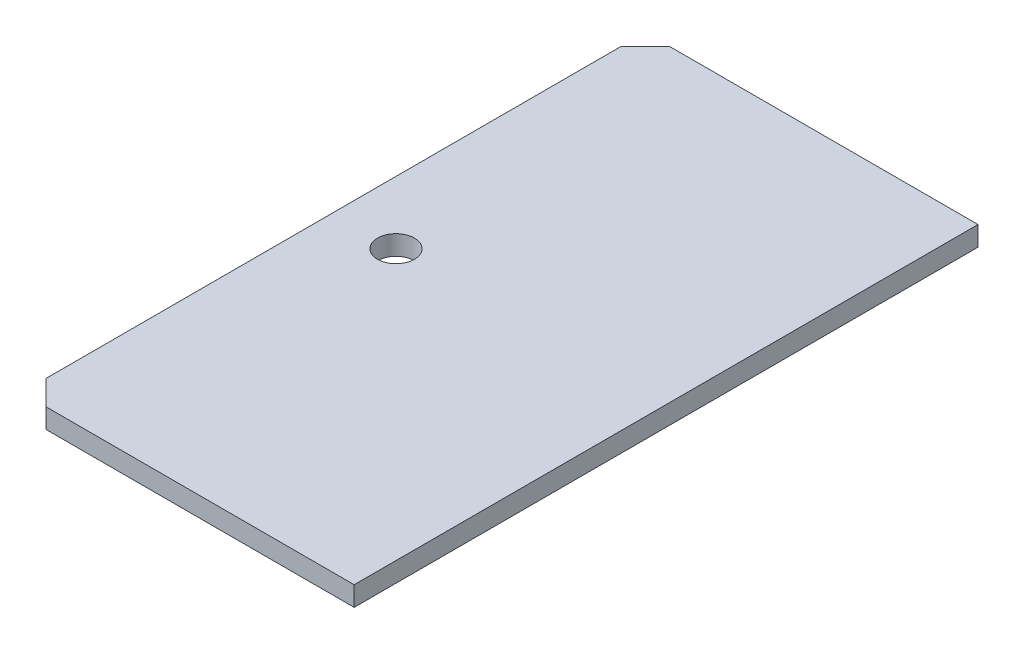
from build123d import *

# Parameters (mm, degrees)
SKETCH1_W           = 81.28
SKETCH1_H           = 50.8
BOSS_EXTRUDE1_DEPTH = 1.6002
SKETCH2_R           = 1.5
CUT_EXTRUDE1_DEPTH  = 1.6002
CHAMFER1_SIZE       = 2
CUT_EXTRUDE2_DEPTH  = 10


with BuildPart() as part:
    # Sketch1 → Boss-Extrude1 (new body)
    with BuildSketch(Plane(origin=(0, 0, 0), x_dir=(1, 0, 0), z_dir=(0, 1, 0))):
        Rectangle(SKETCH1_W, SKETCH1_H)
    extrude(amount=BOSS_EXTRUDE1_DEPTH)

    # Sketch2 → Cut-Extrude1 (cut)
    with BuildSketch(Plane(origin=(0, 1.6002, 0), x_dir=(1, 0, 0), z_dir=(0, 1, 0))):
        with Locations((-35.54, 0)):
            Circle(SKETCH2_R)
        with Locations((35.56, 0)):
            Circle(SKETCH2_R)
        Circle(SKETCH2_R)
    extrude(amount=-CUT_EXTRUDE1_DEPTH, mode=Mode.SUBTRACT)

    # Chamfer1
    chamfer1_edges = [part.edges().sort_by_distance(p)[0] for p in [
        (40.64, 0.8001, 25.4),
        (-40.64, 0.8001, 25.4),
        (-40.64, 0.8001, -25.4),
        (40.64, 0.8001, -25.4),
    ]]
    chamfer(chamfer1_edges, length=CHAMFER1_SIZE)

    # Sketch3 → Cut-Extrude2 (cut)
    with BuildSketch(Plane.XZ):
        Polygon((-13.546666667, 25.4), (-13.546666667, -25.4), (38.64, -25.4), (40.64, -23.4), (40.64, 23.4), (38.64, 25.4), align=None)
    extrude(amount=-CUT_EXTRUDE2_DEPTH, mode=Mode.SUBTRACT)


solid = part.part
